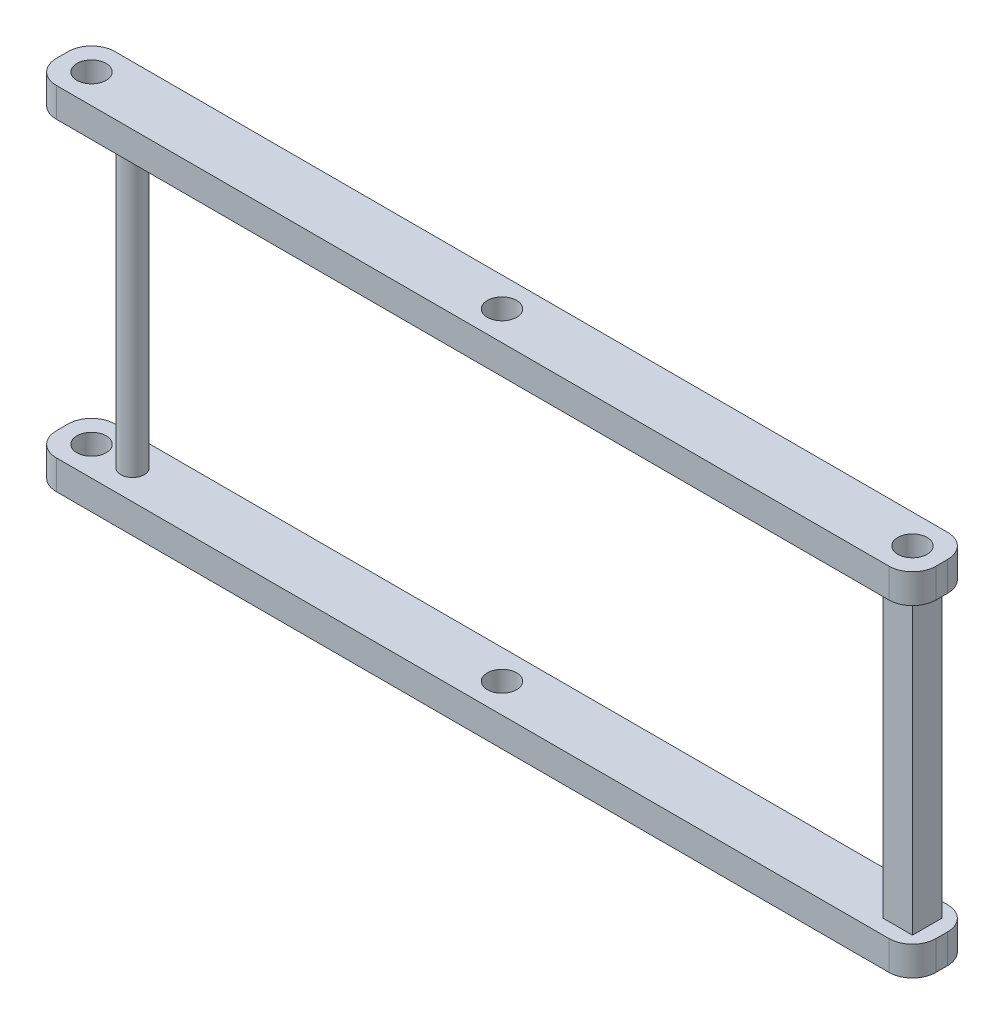
from build123d import *

# Parameters (mm, degrees)
CROQUIS1_W                    = 150
CROQUIS1_H                    = 10
CROQUIS1_R                    = 2.5
SALIENTE_EXTRUIR1_DEPTH       = 5
REDONDEO1_R                   = 4
CROQUIS2_R                    = 2
CROQUIS2_W                    = 5
CROQUIS2_H                    = 5
SALIENTE_EXTRUIR2_DEPTH       = 50
SALIENTE_EXTRUIR2_DEPTH_BACK  = 0.01
CROQUIS3_R                    = 2.5
SALIENTE_EXTRUIR10_DEPTH      = 5
SALIENTE_EXTRUIR10_DEPTH_BACK = 0.001


with BuildPart() as part:
    # Croquis1 → Saliente-Extruir1 (new body)
    with BuildSketch(Plane(origin=(0, 0, 0), x_dir=(1, 0, 0), z_dir=(0, 1, 0))):
        Rectangle(CROQUIS1_W, CROQUIS1_H)
        with Locations((-70, 0)):
            Circle(CROQUIS1_R, mode=Mode.SUBTRACT)
        with Locations((70, 0)):
            Circle(CROQUIS1_R, mode=Mode.SUBTRACT)
        Circle(CROQUIS1_R, mode=Mode.SUBTRACT)
    extrude(amount=SALIENTE_EXTRUIR1_DEPTH)

    # Redondeo1
    redondeo1_edges = [part.edges().sort_by_distance(p)[0] for p in [
        (75, 2.5, 5),
        (-75, 2.5, 5),
        (-75, 2.5, -5),
        (75, 2.5, -5),
    ]]
    fillet(redondeo1_edges, radius=REDONDEO1_R)

    # Croquis2 → Saliente-Extruir2 (add, two sides)
    with BuildSketch(Plane(origin=(0, 5, 0), x_dir=(1, 0, 0), z_dir=(0, 1, 0))) as saliente_extruir2_sk:
        with Locations((-63, 0)):
            Circle(CROQUIS2_R)
        with Locations((70, 0)):
            Rectangle(CROQUIS2_W, CROQUIS2_H)
    extrude(amount=SALIENTE_EXTRUIR2_DEPTH)
    extrude(saliente_extruir2_sk.sketch, amount=-SALIENTE_EXTRUIR2_DEPTH_BACK)

    # Croquis3 → Saliente-Extruir10 (add, two sides)
    with BuildSketch(Plane(origin=(0, 55, 0), x_dir=(1, 0, 0), z_dir=(0, 1, 0))) as saliente_extruir10_sk:
        with BuildLine():
            Line((-75, 1), (-75, -1))
            ThreePointArc((-75, -1), (-73.828427125, -3.828427125), (-71, -5))
            Line((-71, -5), (71, -5))
            ThreePointArc((71, -5), (73.828427125, -3.828427125), (75, -1))
            Line((75, -1), (75, 1))
            ThreePointArc((75, 1), (73.828427125, 3.828427125), (71, 5))
            Line((71, 5), (-71, 5))
            ThreePointArc((-71, 5), (-73.828427125, 3.828427125), (-75, 1))
        make_face()
        with Locations((70, 0)):
            Circle(CROQUIS3_R, mode=Mode.SUBTRACT)
        Circle(CROQUIS3_R, mode=Mode.SUBTRACT)
        with Locations((-70, 0)):
            Circle(CROQUIS3_R, mode=Mode.SUBTRACT)
    extrude(amount=SALIENTE_EXTRUIR10_DEPTH)
    extrude(saliente_extruir10_sk.sketch, amount=-SALIENTE_EXTRUIR10_DEPTH_BACK)


solid = part.part
